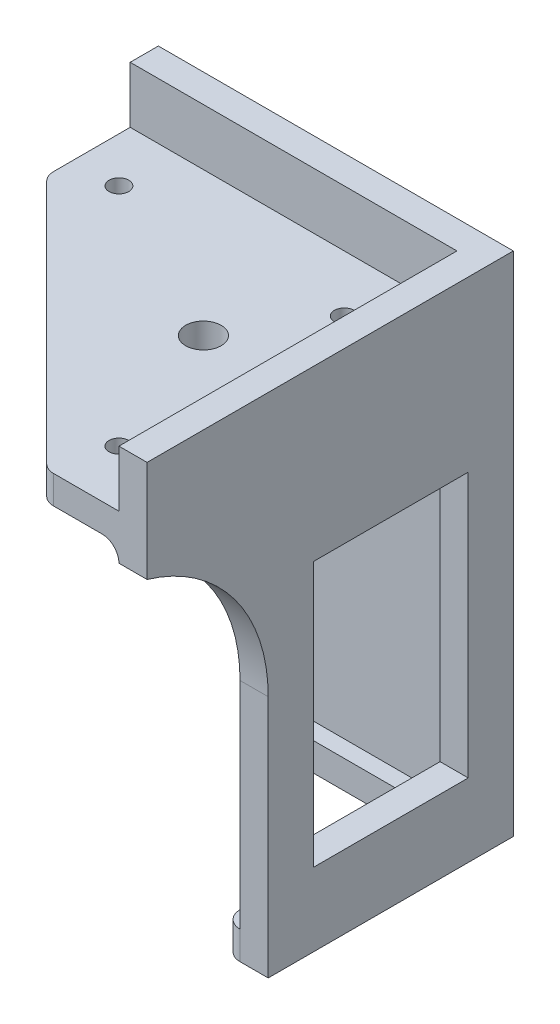
from build123d import *

# Parameters (mm, degrees)
SALIENTE_EXTRUIR1_DEPTH = 5
CROQUIS2_W              = 5
CROQUIS2_H              = 90
SALIENTE_EXTRUIR2_DEPTH = 60
CORTAR_EXTRUIR1_DEPTH   = 5
SALIENTE_EXTRUIR3_DEPTH = 5
REDONDEO1_R             = 3
CROQUIS5_W              = 58
CROQUIS5_H              = 5
SALIENTE_EXTRUIR4_DEPTH = 60
CORTAR_EXTRUIR2_DEPTH   = 5
REDONDEO2_R             = 3
REDONDEO3_R             = 3
CROQUIS7_R              = 1.75
CROQUIS7_R_2            = 3.15
CORTAR_EXTRUIR3_DEPTH   = 5
CROQUIS8_W              = 27.5
CROQUIS8_H              = 47
CORTAR_EXTRUIR4_DEPTH   = 5


with BuildPart() as part:
    # Croquis1 → Saliente-Extruir1 (new body)
    with BuildSketch(Plane.XY):
        with BuildLine():
            Line((-63, 0), (0, 0))
            Line((0, 0), (0, -90))
            Line((0, -90), (-33, -90))
            Line((-33, -90), (-33, -48))
            ThreePointArc((-33, -48), (-41.786797, -26.786797), (-63, -18))
            Line((-63, -18), (-63, 0))
        make_face()
    extrude(amount=SALIENTE_EXTRUIR1_DEPTH)

    # Croquis2 → Saliente-Extruir2 (add)
    with BuildSketch(Plane.XY.offset(5)):
        with Locations((-2.5, -45)):
            Rectangle(CROQUIS2_W, CROQUIS2_H)
    extrude(amount=SALIENTE_EXTRUIR2_DEPTH)

    # Croquis3 → Cortar-Extruir1 (cut)
    with BuildSketch(Plane(origin=(0, 0, 0), x_dir=(0, 0, -1), z_dir=(1, 0, 0))):
        with BuildLine():
            Line((-65, -90), (-43.5, -90))
            Line((-43.5, -90), (-43.5, -46.770645))
            ThreePointArc((-43.5, -46.770645), (-49.46877, -28.81236), (-65, -18))
            Line((-65, -18), (-65, -90))
        make_face()
    extrude(amount=-CORTAR_EXTRUIR1_DEPTH, mode=Mode.SUBTRACT)

    # Croquis4 → Saliente-Extruir3 (add)
    with BuildSketch(Plane.XZ.offset(90)):
        Polygon((-33, 8), (-8, 8), (-8, 43.5), (-5, 43.5), (-5, 5), (-33, 5), align=None)
    extrude(amount=-SALIENTE_EXTRUIR3_DEPTH)

    # Redondeo1
    redondeo1_edges = [part.edges().sort_by_distance(p)[0] for p in [
        (-33, -87.5, 8),
        (-8, -87.5, 43.5),
    ]]
    fillet(redondeo1_edges, radius=REDONDEO1_R)

    # Croquis5 → Saliente-Extruir4 (add)
    with BuildSketch(Plane.XY.offset(5)):
        with Locations((-34, -12.5)):
            Rectangle(CROQUIS5_W, CROQUIS5_H)
    extrude(amount=SALIENTE_EXTRUIR4_DEPTH)

    # Croquis6 → Cortar-Extruir2 (cut)
    with BuildSketch(Plane(origin=(0, -10, 0), x_dir=(1, 0, 0), z_dir=(0, 1, 0))):
        Polygon((-63, -19.817641), (-17.817641, -65), (-63, -65), align=None)
    extrude(amount=-CORTAR_EXTRUIR2_DEPTH, mode=Mode.SUBTRACT)

    # Redondeo2
    redondeo2_edges = [part.edges().sort_by_distance(p)[0] for p in [
        (-63, -12.5, 19.817641),
        (-17.817641, -12.5, 65),
    ]]
    fillet(redondeo2_edges, radius=REDONDEO2_R)

    # Redondeo3
    redondeo3_edges = [part.edges().sort_by_distance(p)[0] for p in [
        (-34, -15, 5),
        (-5, -15, 35),
        (-5, -50, 5),
    ]]
    fillet(redondeo3_edges, radius=REDONDEO3_R)

    # Croquis7 → Cortar-Extruir3 (cut)
    with BuildSketch(Plane(origin=(0, -10, 0), x_dir=(1, 0, 0), z_dir=(0, 1, 0))):
        with Locations((-15, -55)):
            Circle(CROQUIS7_R)
        with Locations((-15, -15)):
            Circle(CROQUIS7_R)
        with Locations((-55, -15)):
            Circle(CROQUIS7_R)
        with Locations((-24.5, -30.5)):
            Circle(CROQUIS7_R_2)
    extrude(amount=-CORTAR_EXTRUIR3_DEPTH, mode=Mode.SUBTRACT)

    # Croquis8 → Cortar-Extruir4 (cut)
    with BuildSketch(Plane(origin=(0, 0, 0), x_dir=(0, 0, -1), z_dir=(1, 0, 0))):
        with Locations((-21.75, -53.5)):
            Rectangle(CROQUIS8_W, CROQUIS8_H)
    extrude(amount=-CORTAR_EXTRUIR4_DEPTH, mode=Mode.SUBTRACT)


solid = part.part
